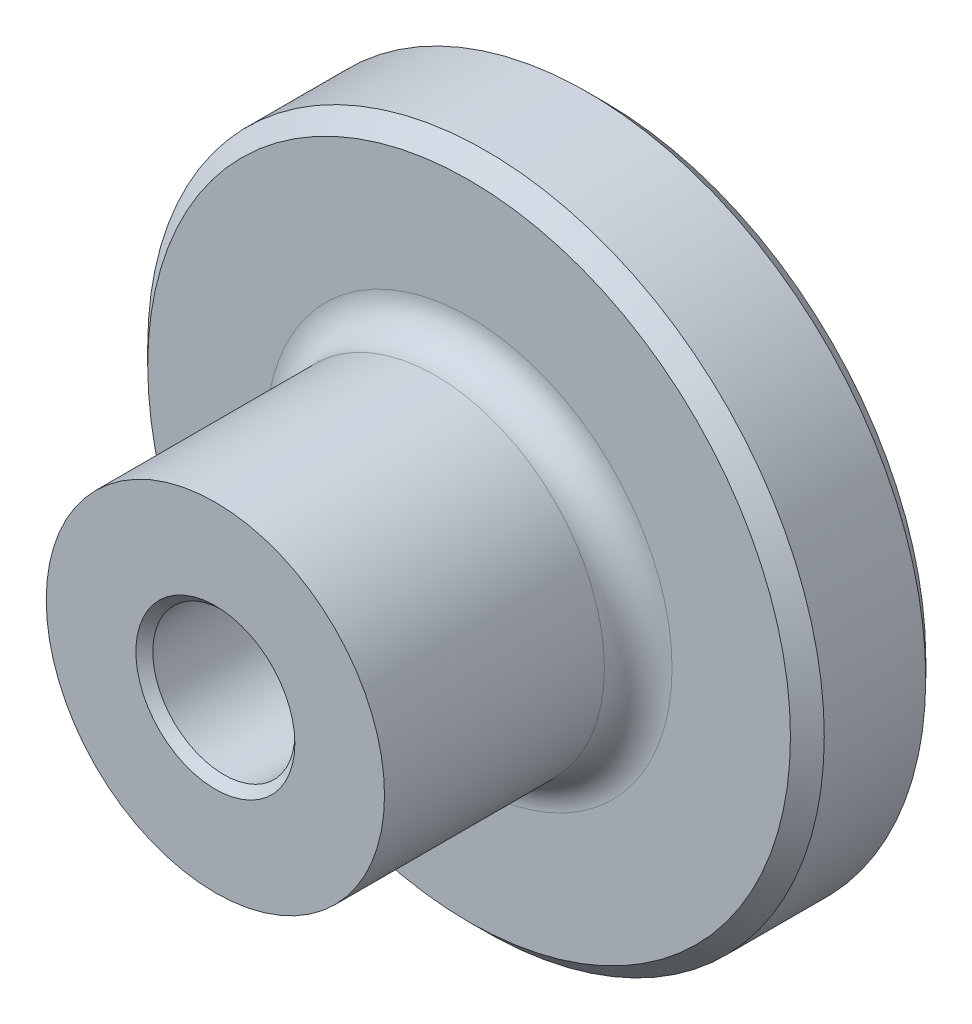
from build123d import *

# Parameters (mm, degrees)
CROQUIS1_R              = 10
CROQUIS1_R_2            = 2.1
SALIENTE_EXTRUIR1_DEPTH = 4
CROQUIS2_R              = 5
CROQUIS2_R_2            = 2.1
SALIENTE_EXTRUIR2_DEPTH = 7.5
CHAFL_N1_SIZE           = 0.5
REDONDEO1_R             = 1
CHAFL_N2_SIZE           = 0.25


with BuildPart() as part:
    # Croquis1 → Saliente-Extruir1 (new body)
    with BuildSketch(Plane.XY):
        Circle(CROQUIS1_R)
        Circle(CROQUIS1_R_2, mode=Mode.SUBTRACT)
    extrude(amount=SALIENTE_EXTRUIR1_DEPTH)

    # Croquis2 → Saliente-Extruir2 (add)
    with BuildSketch(Plane.XY.offset(4)):
        Circle(CROQUIS2_R)
        Circle(CROQUIS2_R_2, mode=Mode.SUBTRACT)
    extrude(amount=SALIENTE_EXTRUIR2_DEPTH)

    # Chaflán1
    chafl_n1_edges = [part.edges().sort_by_distance(p)[0] for p in [
        (-10, 0, 0),
        (-10, 0, 4),
    ]]
    chamfer(chafl_n1_edges, length=CHAFL_N1_SIZE)

    # Redondeo1
    redondeo1_edges = [part.edges().sort_by_distance(p)[0] for p in [
        (-5, 0, 4),
    ]]
    fillet(redondeo1_edges, radius=REDONDEO1_R)

    # Chaflán2
    chafl_n2_edges = [part.edges().sort_by_distance(p)[0] for p in [
        (-2.1, 0, 11.5),
    ]]
    chamfer(chafl_n2_edges, length=CHAFL_N2_SIZE)


solid = part.part
